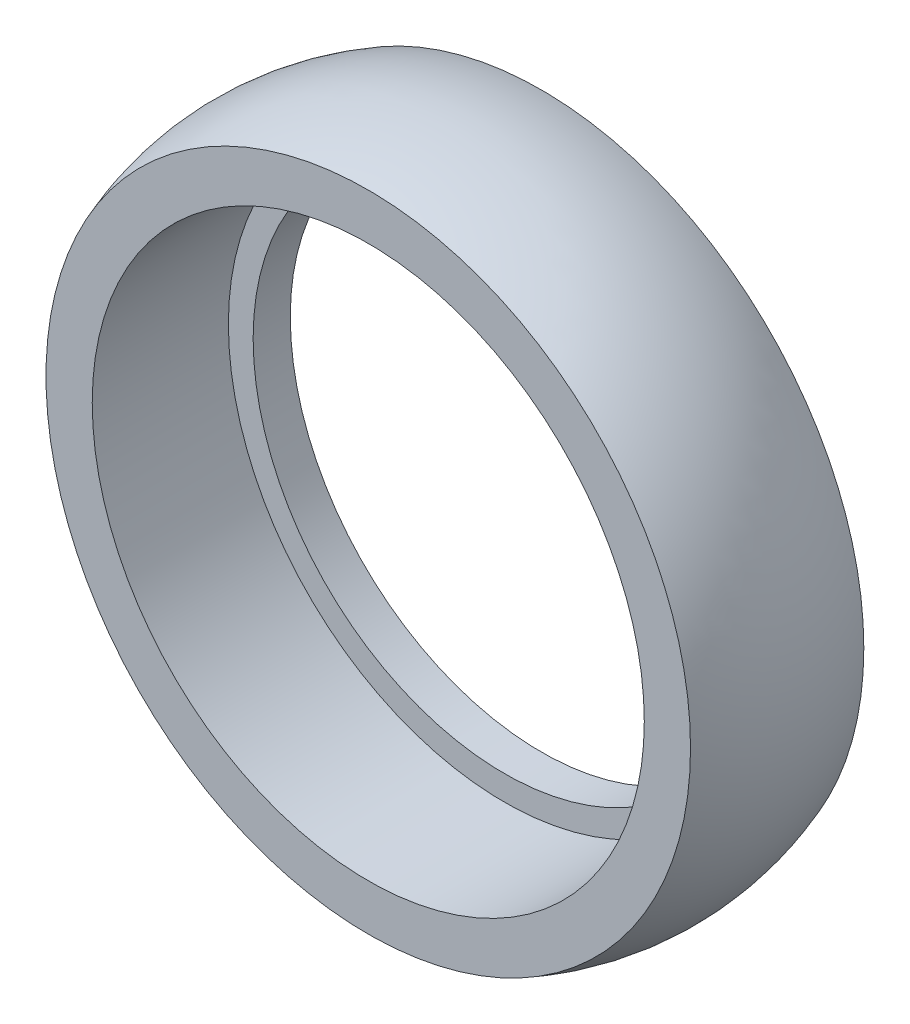
from build123d import *


with BuildPart() as part:
    # Sketch2 → Revolve1 (revolve)
    with BuildSketch(Plane(origin=(0, 0, 0), x_dir=(0, 0, -1), z_dir=(1, 0, 0))):
        with BuildLine():
            Line((-7, 13.017496998), (-7, 11.15))
            Line((-7, 11.15), (-1.5, 11.15))
            Line((-1.5, 11.15), (-1.5, 10.15))
            Line((-1.5, 10.15), (0, 10.15))
            Line((0, 10.15), (0, 13.017496998))
            ThreePointArc((0, 13.017496998), (-3.5, 13.65), (-7, 13.017496998))
        make_face()
    revolve(axis=Axis((0, 0, 0), (0, 0, -1)))


solid = part.part
